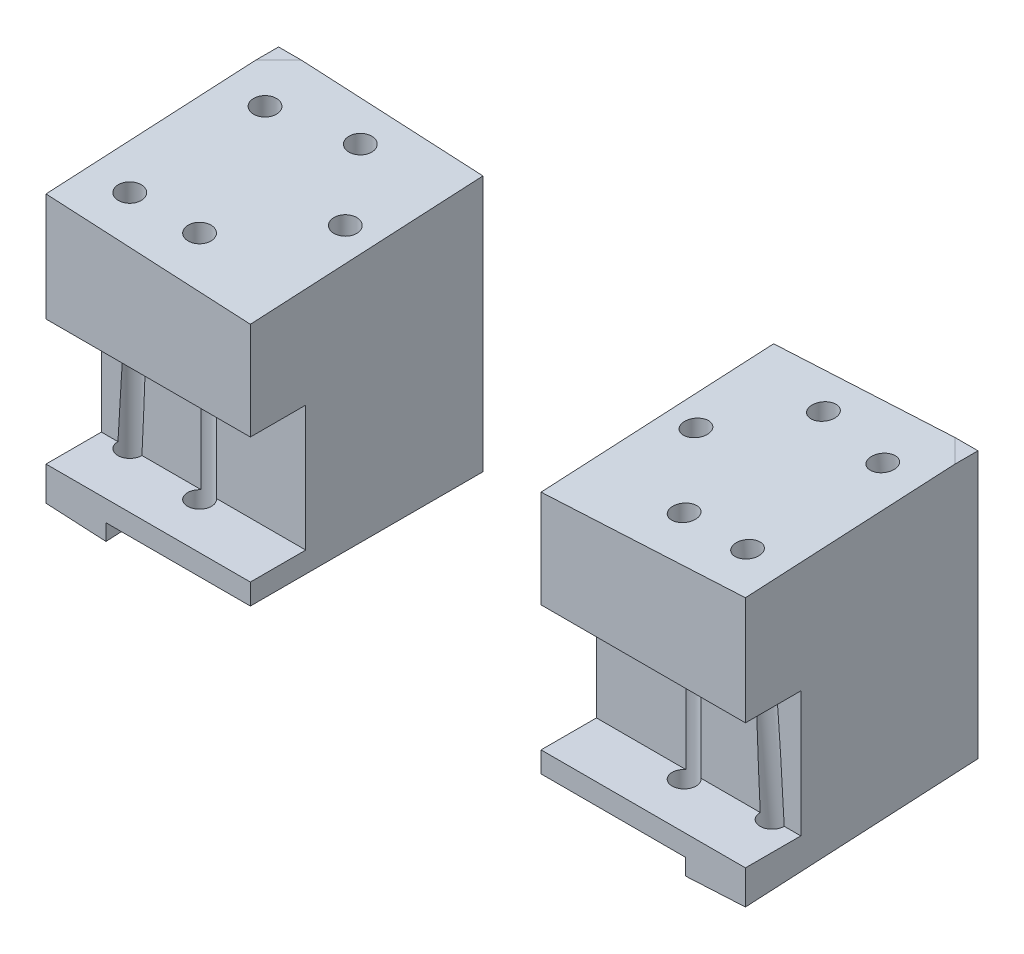
from build123d import *

# Parameters (mm, degrees)
BOSS_EXTRUDE1_START      = 13.335
SKETCH1_W                = 23.438902935
SKETCH1_H                = 26.673096393
BOSS_EXTRUDE1_DEPTH      = 33.02
SKETCH2_W                = 22.160694563
SKETCH2_H                = 4.328355372
CUT_EXTRUDE1_DEPTH       = 30.48
SKETCH3_R                = 1.3716
A_ARM_HOLES_DEPTH        = 54.921009736
STEERING_ARM_NOTCH_DEPTH = 30.48
SKETCH5_R                = 1.3716
ANCHOR_HOLES_DEPTH       = 30.48


with BuildPart() as part:
    # Sketch1 → Boss-Extrude1 (new body)
    with BuildSketch(Plane(origin=(0, 0, 0), x_dir=(1, 0, 0), z_dir=(0, 1, 0)).offset(BOSS_EXTRUDE1_START)):
        with Locations((-28.389945686, 0.006605288)):
            Rectangle(SKETCH1_W, SKETCH1_H)
    extrude(amount=BOSS_EXTRUDE1_DEPTH)

    # SurfaceCut1
    split(bisect_by=Plane(origin=(2.277212667, 43.451806158, 2.28033779), x_dir=(-0.9986332910992534, 0.05219240899906097, 0.00273904201295754), z_dir=(-0.052264231633823974, -0.9972609476841369, -0.0523359562429442)), keep=Keep.TOP)

    # SurfaceCut2
    split(bisect_by=Plane(origin=(0.67596727, 12.898223874, 0.676894931), x_dir=(0.9986332910992533, -0.05219240899906121, -0.002739042012957531), z_dir=(0.052264231633824224, 0.9972609476841369, 0.05233595624294378)), keep=Keep.TOP)

    # Sketch2 → Cut-Extrude1 (cut)
    with BuildSketch(Plane(origin=(0, 0, -13.343153485), x_dir=(-1, 0, 0), z_dir=(0, 0, -1))):
        with Locations((22.148410537, 13.710822314)):
            Rectangle(SKETCH2_W, SKETCH2_H)
    extrude(amount=-CUT_EXTRUDE1_DEPTH, mode=Mode.SUBTRACT)

    # Sketch3 → A-Arm Holes (cut, through all)
    with BuildSketch(Plane(origin=(2.277212667, 43.451806158, 2.28033779), x_dir=(0.9986332910992534, -0.052192408999060975, -0.0027390420129575405), z_dir=(0.05226423163382398, 0.9972609476841369, 0.0523359562429442))):
        with Locations(Location((-37.754796672, -6.028488857, 0), (0, 0, 270))):
            Circle(SKETCH3_R)
        with Locations(Location((-37.754796672, 9.502629761, 0), (0, 0, 270))):
            Circle(SKETCH3_R)
    extrude(amount=-A_ARM_HOLES_DEPTH, mode=Mode.SUBTRACT)

    # Sketch4 → Steering Arm Notch (cut)
    with BuildSketch(Plane(origin=(-16.670494218, 0, 0), x_dir=(0, 0, -1), z_dir=(1, 0, 0))):
        Polygon((-13.329942908, 18.263758385), (-6.979942908, 18.263758385), (-6.979942908, 32.664722656), (-13.329942908, 32.664722656), (-16.160324711, 30.773717369), (-16.160324711, 16.881221926), align=None)
    extrude(amount=-STEERING_ARM_NOTCH_DEPTH, mode=Mode.SUBTRACT)

    # Sketch5 → Anchor Holes (cut)
    with BuildSketch(Plane.XZ.offset(-15.875)):
        with Locations(Location((-26.555704526, -9.169971692, 0), (0, 0, 270))):
            Circle(SKETCH5_R)
        with Locations(Location((-27.786476371, 8.040568412, 0), (0, 0, 270))):
            Circle(SKETCH5_R)
        with Locations(Location((-20.105647723, -0.999384842, 0), (0, 0, 270))):
            Circle(SKETCH5_R)
    extrude(amount=-ANCHOR_HOLES_DEPTH, mode=Mode.SUBTRACT)


with BuildPart() as body_2:
    # Mirror3: mirrored copy
    add(part.part.mirror(Plane(origin=(0, 0, 0), x_dir=(0, 0, 1), z_dir=(1, 0, 0))))


solid = Compound([part.part, body_2.part])
